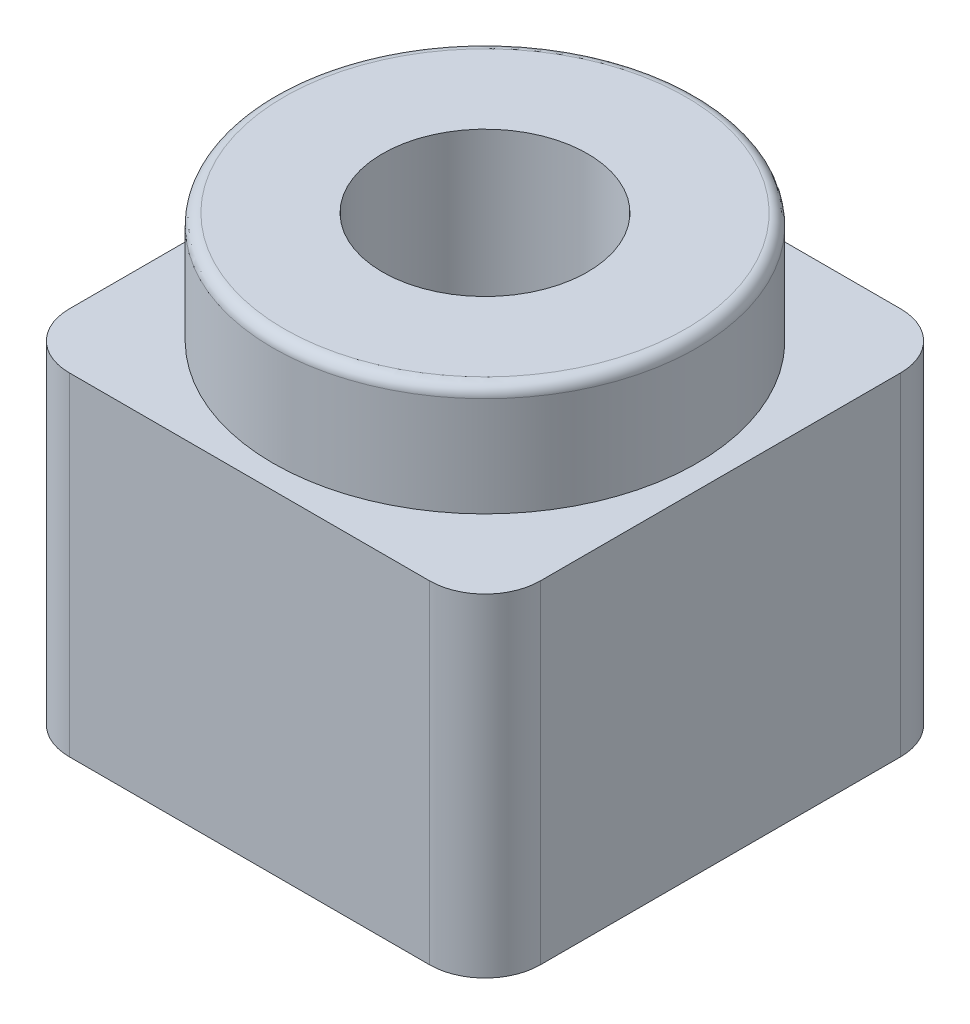
from build123d import *

# Parameters (mm, degrees)
SKETCH3_BASE_W      = 8.5
SKETCH3_BASE_H      = 8.5
BOSS_EXTRUDE1_DEPTH = 6
SKETCH5_INSERT_R    = 3.825
BOSS_EXTRUDE2_DEPTH = 2
SKETCH6_HOLE_R      = 1.85
CUT_EXTRUDE1_DEPTH  = 9
FILLET1_R           = 1
FILLET2_R           = 1
FILLET3_R           = 0.2


with BuildPart() as part:
    # Sketch3 Base → Boss-Extrude1 (new body)
    with BuildSketch(Plane(origin=(0, 0, 0), x_dir=(1, 0, 0), z_dir=(0, 1, 0))):
        Rectangle(SKETCH3_BASE_W, SKETCH3_BASE_H)
    extrude(amount=BOSS_EXTRUDE1_DEPTH)

    # Sketch5 Insert → Boss-Extrude2 (add)
    with BuildSketch(Plane(origin=(0, 6, 0), x_dir=(1, 0, 0), z_dir=(0, 1, 0))):
        with Locations(Location((0, 0, 0), (0, 0, 270))):  # turned: the seam where the file's is
            Circle(SKETCH5_INSERT_R)
    extrude(amount=BOSS_EXTRUDE2_DEPTH)

    # Sketch6 Hole → Cut-Extrude1 (cut, through all)
    with BuildSketch(Plane(origin=(0, 8, 0), x_dir=(1, 0, 0), z_dir=(0, 1, 0))):
        with Locations(Location((0, 0, 0), (0, 0, 270))):  # turned: the seam where the file's is
            Circle(SKETCH6_HOLE_R)
    extrude(amount=-CUT_EXTRUDE1_DEPTH, mode=Mode.SUBTRACT)

    # Fillet1
    fillet1_edges = [part.edges().sort_by_distance(p)[0] for p in [
        (4.25, 3, -4.25),
        (4.25, 3, 4.25),
        (-4.25, 3, 4.25),
    ]]
    fillet(fillet1_edges, radius=FILLET1_R)

    # Fillet2
    fillet2_edges = [part.edges().sort_by_distance(p)[0] for p in [
        (-4.25, 3, -4.25),
    ]]
    fillet(fillet2_edges, radius=FILLET2_R)

    # Fillet3
    fillet3_edges = [part.edges().sort_by_distance(p)[0] for p in [
        (0, 8, -3.825),
    ]]
    fillet(fillet3_edges, radius=FILLET3_R)


solid = part.part
